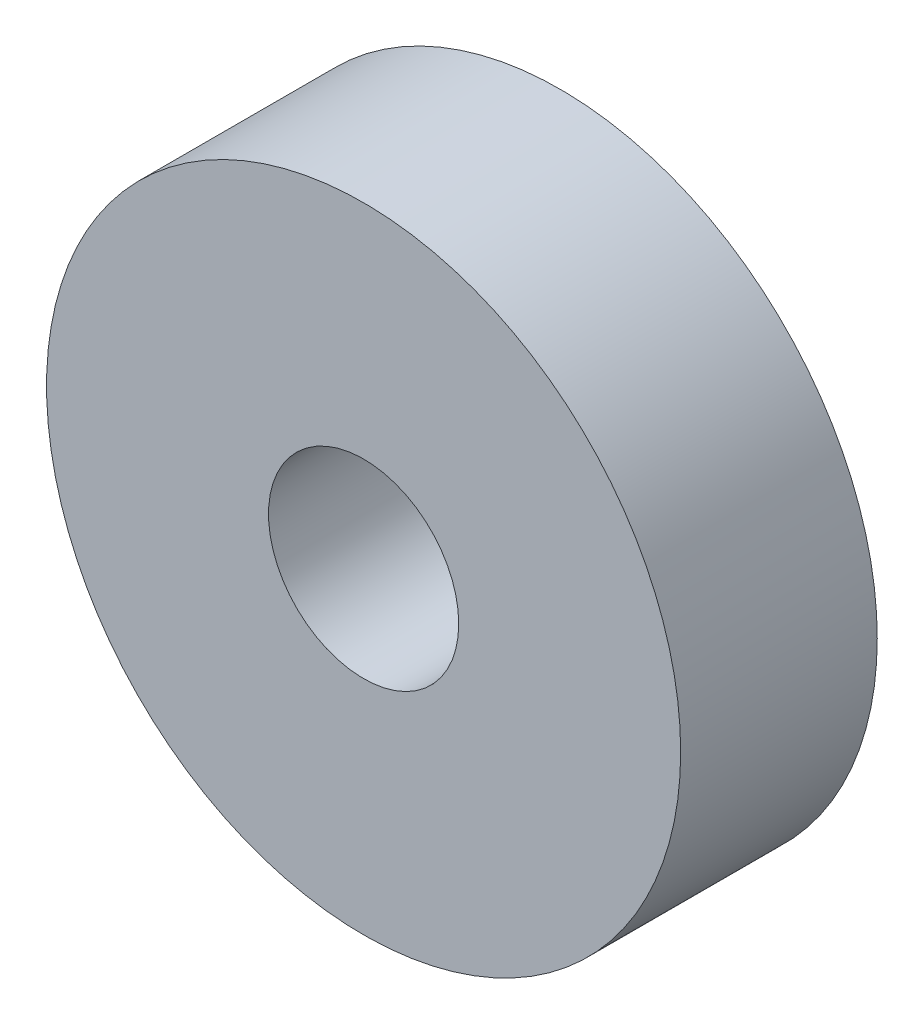
from build123d import *

# Parameters (mm, degrees)
SKETCH1_R           = 50
BOSS_EXTRUDE1_DEPTH = 31
SKETCH2_R           = 15
CUT_EXTRUDE1_DEPTH  = 32


with BuildPart() as part:
    # Sketch1 → Boss-Extrude1 (new body)
    with BuildSketch(Plane.XY):
        Circle(SKETCH1_R)
    extrude(amount=BOSS_EXTRUDE1_DEPTH)

    # Sketch2 → Cut-Extrude1 (cut, through all)
    with BuildSketch(Plane.XY.offset(31)):
        Circle(SKETCH2_R)
    extrude(amount=-CUT_EXTRUDE1_DEPTH, mode=Mode.SUBTRACT)


solid = part.part
